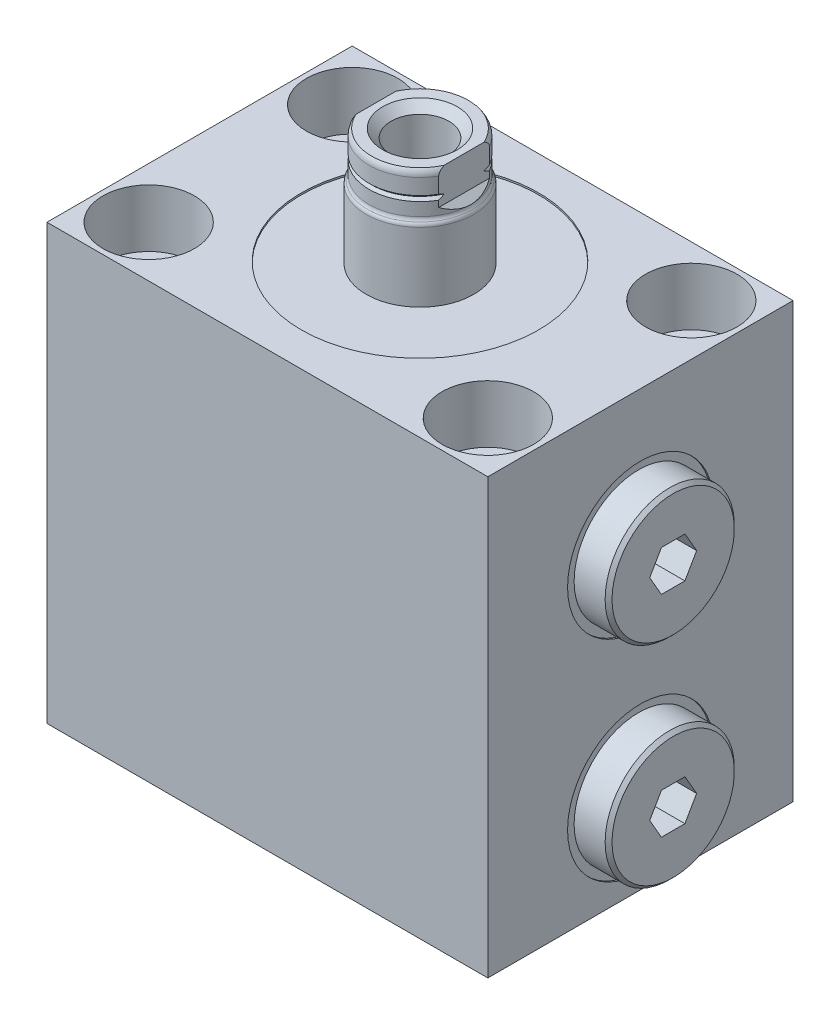
from build123d import *

# Parameters (mm, degrees)
SKETCH1_W                  = 65
SKETCH1_H                  = 45
EXTRUDE1_DEPTH             = 64
SKETCH2_R                  = 17.5
CUT_EXTRUDE1_DEPTH         = 0.254
CHAMFER1_SIZE              = 0.508
CUT_EXTRUDE2_DEPTH         = 5.9944
LPATTERN1_COUNT            = 2
LPATTERN1_PITCH            = 31
CHAMFER1_OF_LPATTERN1_SIZE = 0.508
SKETCH7_R                  = 0.889
LPATTERN2_COUNT            = 2
LPATTERN2_PITCH            = 25
CUT_EXTRUDE3_DEPTH         = 23.5
CUT_EXTRUDE3_DEPTH_BACK    = 23.5
HOLE1_D                    = 8.509
HOLE1_CBORE_D              = 13.487
HOLE1_CBORE_DEPTH          = 8.509


with BuildPart() as part:
    # Sketch1 → Extrude1 (new body)
    with BuildSketch(Plane(origin=(0, 0, 0), x_dir=(1, 0, 0), z_dir=(0, 1, 0))):
        Rectangle(SKETCH1_W, SKETCH1_H)
    extrude(amount=EXTRUDE1_DEPTH)

    # Sketch2 → Cut-Extrude1 (cut)
    with BuildSketch(Plane(origin=(0, 64, 0), x_dir=(1, 0, 0), z_dir=(0, 1, 0))):
        with Locations(Location((0, 0, 0), (0, 0, 270))):  # turned: the seam where the file's is
            Circle(SKETCH2_R)
    extrude(amount=-CUT_EXTRUDE1_DEPTH, mode=Mode.SUBTRACT)

    # Sketch3 → Cut-Revolve1 (revolve, cut)
    with BuildSketch(Plane.XY, mode=Mode.PRIVATE) as cut_revolve1_sk:
        Polygon((32.5, 44), (32.5, 33.256), (32.246, 33.256), (32.246, 37.3452), (31.5348, 38.0564), (16.752, 38.0564), (16.752, 44), align=None)
    cut_revolve1 = revolve(cut_revolve1_sk.sketch.rotate(Axis((-6.847979502, 44, 0), (1, 0, 0)), 270), axis=Axis((-6.847979502, 44, 0), (1, 0, 0)), mode=Mode.SUBTRACT)  # turned: the seam where the file's is

    # Sketch4 → Revolve1 (revolve)
    with BuildSketch(Plane.XY, mode=Mode.PRIVATE) as revolve1_sk:
        Polygon((20.308, 44), (20.308, 49.9182), (32.246, 49.9182), (32.246, 53.525), (37.326, 53.525), (37.326, 44), align=None)
    revolve1 = revolve(revolve1_sk.sketch.rotate(Axis((8.732572807, 44, 0), (1, 0, 0)), 90), axis=Axis((8.732572807, 44, 0), (1, 0, 0)))  # turned: the seam where the file's is

    # Chamfer1
    chamfer1_edges = [part.edges().sort_by_distance(p)[0] for p in [
        (37.326, 44, -9.525),
    ]]
    chamfer(chamfer1_edges, length=CHAMFER1_SIZE)

    # Sketch5 → Cut-Extrude2 (cut)
    with BuildSketch(Plane(origin=(37.326, 0, 0), x_dir=(0, 0, -1), z_dir=(1, 0, 0))):
        Polygon((1.730434227, 46.9972), (-1.730434227, 46.9972), (-3.460868454, 44), (-1.730434227, 41.0028), (1.730434227, 41.0028), (3.460868454, 44), align=None)
    cut_extrude2 = extrude(amount=-CUT_EXTRUDE2_DEPTH, mode=Mode.SUBTRACT)

    # LPattern1: Cut-Revolve1, Revolve1, Cut-Extrude2 ×2
    with Locations(*[(0, -i * LPATTERN1_PITCH, 0) for i in range(1, LPATTERN1_COUNT)]):
        add(cut_revolve1, mode=Mode.SUBTRACT)
        add(revolve1)
        add(cut_extrude2, mode=Mode.SUBTRACT)

    # Chamfer1 of LPattern1
    chamfer1_of_lpattern1_edges = [part.edges().sort_by_distance(p)[0] for p in [
        (37.326, 13, -9.525),
    ]]
    chamfer(chamfer1_of_lpattern1_edges, length=CHAMFER1_OF_LPATTERN1_SIZE)

    # Sketch6 → Cut-Revolve2 (revolve, cut)
    with BuildSketch(Plane.XY, mode=Mode.PRIVATE) as cut_revolve2_sk:
        Polygon((0, 0), (0, 14.895831126), (1.2446, 14.148), (1.2446, 4.9529), (1.7525, 4.445), (3.2512, 4.445), (3.2512, 1.448), (5.7025, 1.448), (5.7025, 0), align=None)
    cut_revolve2 = revolve(cut_revolve2_sk.sketch.rotate(Axis((0, 0, 0), (0, 1, 0)), 90), axis=Axis((0, 0, 0), (0, 1, 0)), mode=Mode.SUBTRACT)  # turned: the seam where the file's is

    # Sketch7 → Revolve3 (revolve)
    with BuildSketch(Plane.XY, mode=Mode.PRIVATE) as revolve3_sk:
        with Locations((4.814, 0.5844)):
            Circle(SKETCH7_R)
    revolve3 = revolve(revolve3_sk.sketch.rotate(Axis((0, 0, 0), (0, 1, 0)), 90), axis=Axis((0, 0, 0), (0, 1, 0)))  # turned: the seam where the file's is

    # LPattern2: Cut-Revolve2, Revolve3 ×2
    with Locations(*[(-i * LPATTERN2_PITCH, 0, 0) for i in range(1, LPATTERN2_COUNT)]):
        add(cut_revolve2, mode=Mode.SUBTRACT)
        add(revolve3)

    # Sketch8 → Revolve4 (revolve)
    with BuildSketch(Plane.XY, mode=Mode.PRIVATE) as revolve4_sk:
        with BuildLine():
            Line((7.925, 63.746), (7.925, 73.944170942))
            ThreePointArc((7.925, 73.944170942), (7.869881532, 74.228710043), (7.7125, 74.472085471))
            ThreePointArc((7.7125, 74.472085471), (7.555118468, 74.715460899), (7.5, 75))
            Line((7.5, 75), (7.5, 80.0094))
            ThreePointArc((7.5, 80.0094), (7.405612002, 80.537401443), (7.134139733, 81))
            Line((7.134139733, 81), (0, 81))
            Line((0, 81), (0, 63.746))
            Line((0, 63.746), (7.925, 63.746))
        make_face()
    revolve(revolve4_sk.sketch.rotate(Axis((0, 0, 0), (0, 1, 0)), 90), axis=Axis((0, 0, 0), (0, 1, 0)))  # turned: the seam where the file's is

    # Sketch10 → Cut-Revolve3 (revolve, cut)
    with BuildSketch(Plane.XY, mode=Mode.PRIVATE) as cut_revolve3_sk:
        Polygon((5.5, 81), (4.267, 79.767), (4.267, 60.68), (0, 58.116127739), (0, 81), align=None)
    revolve(cut_revolve3_sk.sketch.rotate(Axis((0, 81, 0), (0, 1, 0)), 90), axis=Axis((0, 81, 0), (0, 1, 0)), mode=Mode.SUBTRACT)  # turned: the seam where the file's is

    # Sketch11 → Cut-Revolve4 (revolve, cut)
    with BuildSketch(Plane.XY, mode=Mode.PRIVATE) as cut_revolve4_sk:
        Polygon((7.5, 77.698), (7.119, 77.317), (7.5, 76.936), align=None)
    revolve(cut_revolve4_sk.sketch.rotate(Axis((0, 0, 0), (0, 1, 0)), 90), axis=Axis((0, 0, 0), (0, 1, 0)), mode=Mode.SUBTRACT)  # turned: the seam where the file's is

    # Sketch12 → Cut-Extrude3 (cut, two sides)
    with BuildSketch(Plane.XY) as cut_extrude3_sk:
        Polygon((6.5, 81), (6.5, 76), (7.925, 74.575), (7.925, 81), align=None)
        Polygon((-7.925, 81), (-6.5, 81), (-6.5, 76), (-7.925, 74.575), align=None)
    extrude(amount=CUT_EXTRUDE3_DEPTH, mode=Mode.SUBTRACT)
    extrude(cut_extrude3_sk.sketch, amount=-CUT_EXTRUDE3_DEPTH_BACK, mode=Mode.SUBTRACT)

    # Hole1 (through all)
    with Locations(Plane(origin=(0, 64, 0), x_dir=(-1, 0, 0), z_dir=(0, 1, 0))):
        with Locations((25, 15), (25, -15), (-25, -15), (-25, 15)):
            CounterBoreHole(HOLE1_D / 2, HOLE1_CBORE_D / 2, HOLE1_CBORE_DEPTH)


solid = part.part
